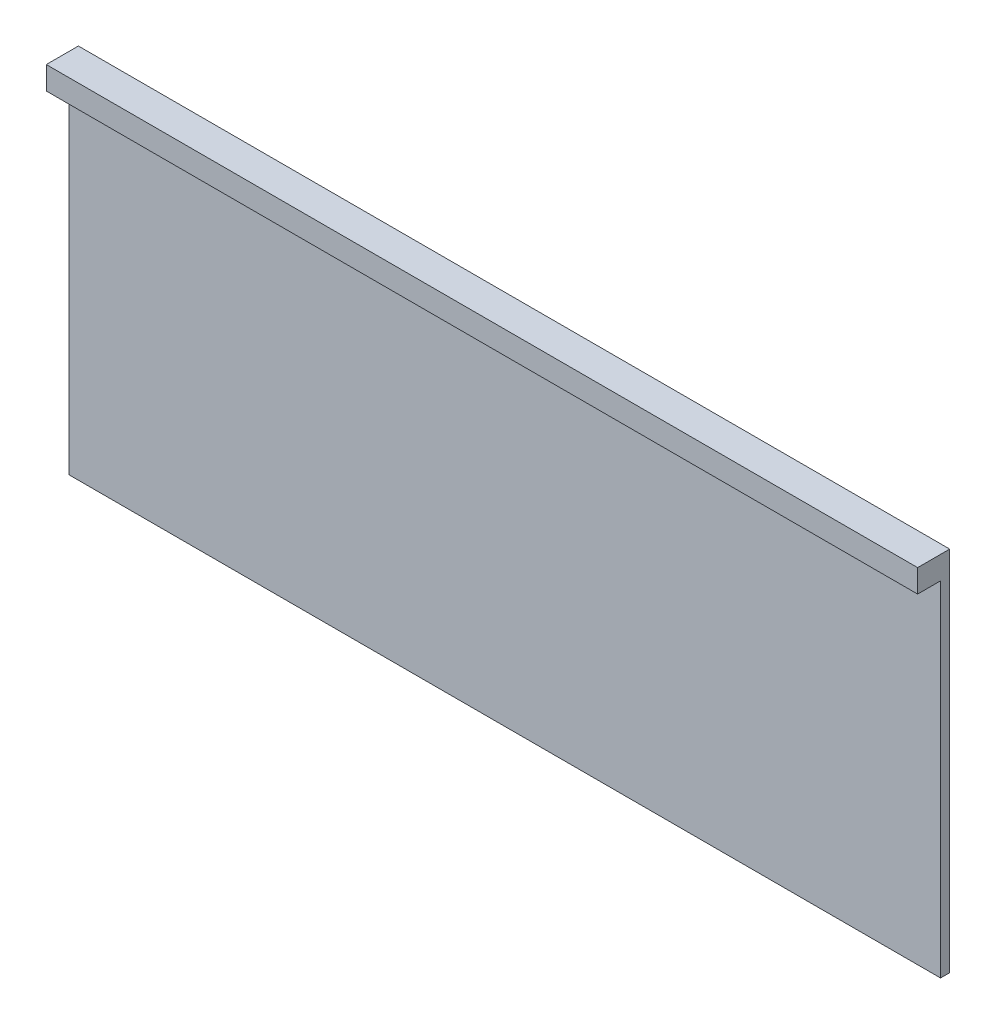
from build123d import *

# Parameters (mm, degrees)
CROQUIS1_W              = 76
CROQUIS1_H              = 32
SALIENTE_EXTRUIR1_DEPTH = 0.8
CROQUIS3_W              = 76
CROQUIS3_H              = 2
SALIENTE_EXTRUIR2_DEPTH = 2


with BuildPart() as part:
    # Croquis1 → Saliente-Extruir1 (new body)
    with BuildSketch(Plane.XY):
        with Locations((-38, 14)):
            Rectangle(CROQUIS1_W, CROQUIS1_H)
    extrude(amount=SALIENTE_EXTRUIR1_DEPTH)

    # Croquis3 → Saliente-Extruir2 (add)
    with BuildSketch(Plane.XY.offset(0.8)):
        with Locations((-38, 29)):
            Rectangle(CROQUIS3_W, CROQUIS3_H)
    extrude(amount=SALIENTE_EXTRUIR2_DEPTH)


solid = part.part
